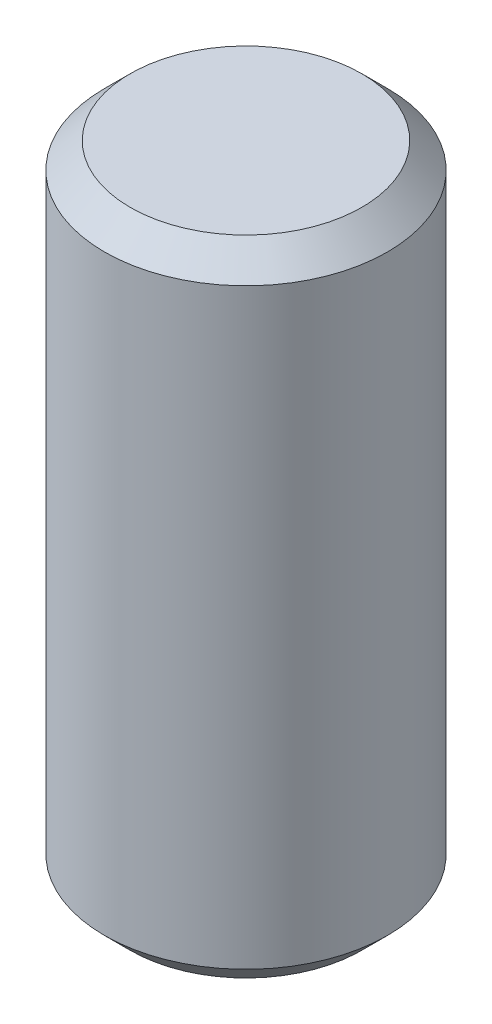
from build123d import *

# Parameters (mm, degrees)
SKETCH1_W     = 2.794
SKETCH1_H     = 12.7
CHAMFER1_SIZE = 0.508


with BuildPart() as part:
    # Sketch1 → Revolve1 (revolve)
    with BuildSketch(Plane.XY):
        with Locations((1.397, 0)):
            Rectangle(SKETCH1_W, SKETCH1_H)
    revolve(axis=Axis((0, 6.080207887, 0), (0, -1, 0)))

    # Chamfer1
    chamfer1_edges = [part.edges().sort_by_distance(p)[0] for p in [
        (-2.794, 6.35, 0),
        (-2.794, -6.35, 0),
    ]]
    chamfer(chamfer1_edges, length=CHAMFER1_SIZE)


solid = part.part
